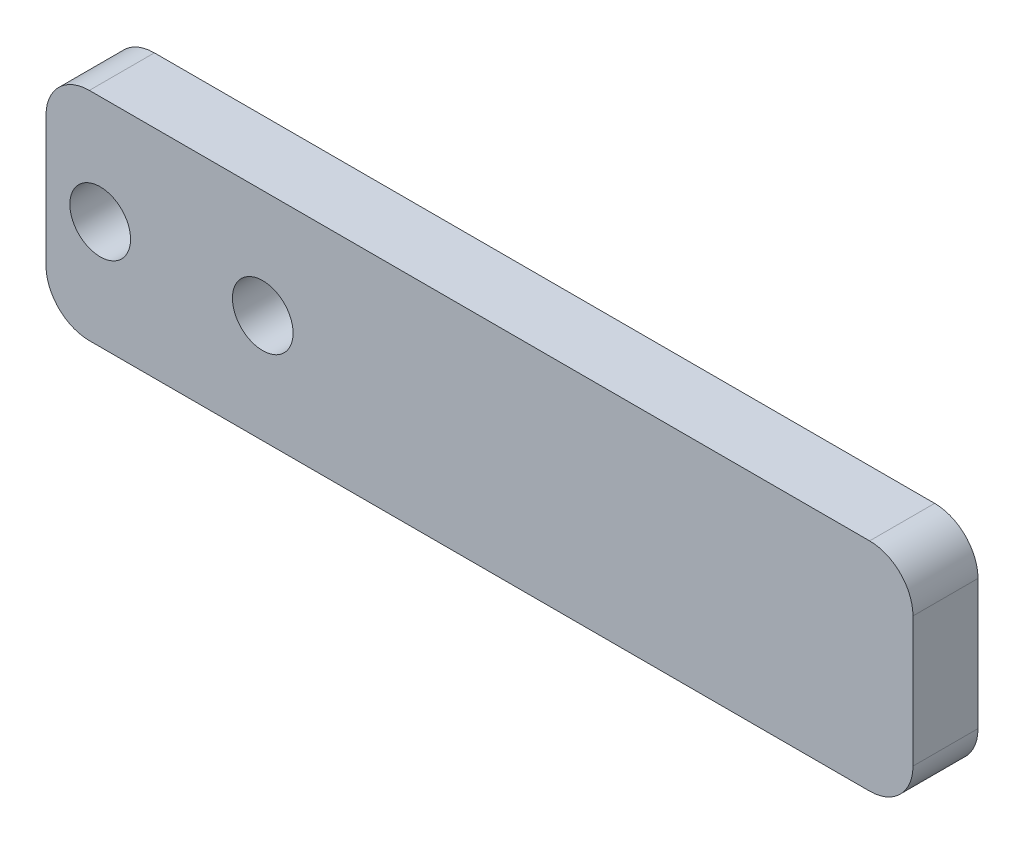
from build123d import *

# Parameters (mm, degrees)
ESQUISSE1_W        = 40
ESQUISSE1_H        = 10
ESQUISSE1_R        = 1.4
BOSS_EXTRU_1_DEPTH = 3
CONG_1_R           = 2


with BuildPart() as part:
    # Esquisse1 → Boss.-Extru.1 (new body)
    with BuildSketch(Plane.XY):
        Rectangle(ESQUISSE1_W, ESQUISSE1_H)
        with Locations((-10, 0)):
            Circle(ESQUISSE1_R, mode=Mode.SUBTRACT)
        with Locations((-17.5, 0)):
            Circle(ESQUISSE1_R, mode=Mode.SUBTRACT)
    extrude(amount=BOSS_EXTRU_1_DEPTH)

    # Congé1
    cong_1_edges = [part.edges().sort_by_distance(p)[0] for p in [
        (20, -5, 1.5),
        (-20, -5, 1.5),
        (-20, 5, 1.5),
        (20, 5, 1.5),
    ]]
    fillet(cong_1_edges, radius=CONG_1_R)


solid = part.part
